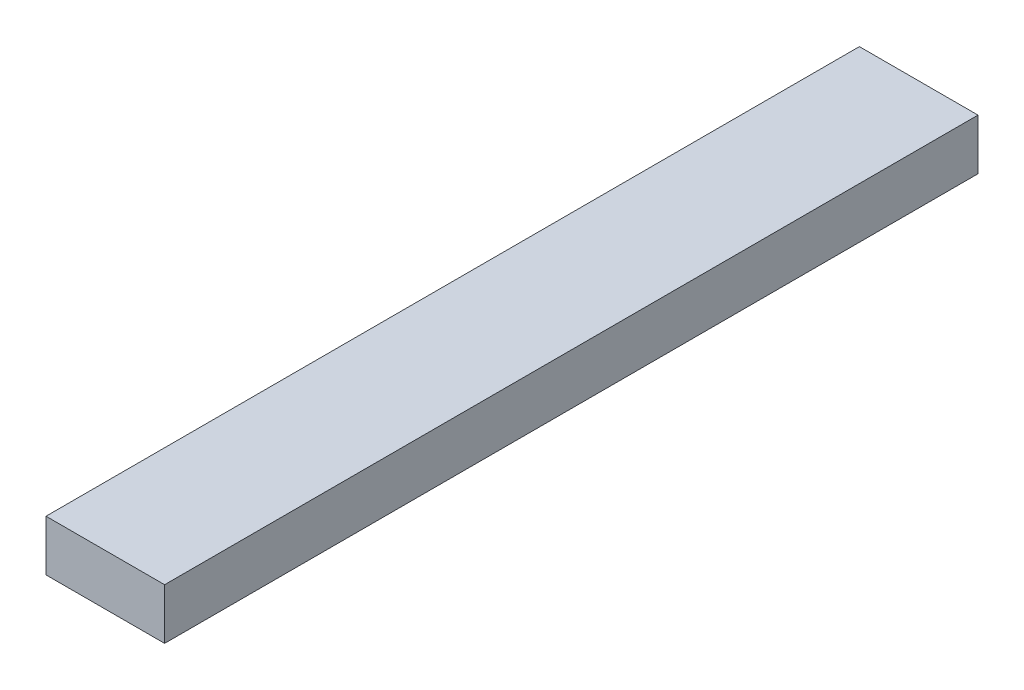
from build123d import *

# Parameters (mm, degrees)
SKETCH1_W           = 88.9
SKETCH1_H           = 38.1
BOSS_EXTRUDE1_DEPTH = 609.6


with BuildPart() as part:
    # Sketch1 → Boss-Extrude1 (new body)
    with BuildSketch(Plane.XY):
        with Locations((44.45, 19.05)):
            Rectangle(SKETCH1_W, SKETCH1_H)
    extrude(amount=BOSS_EXTRUDE1_DEPTH)


solid = part.part
